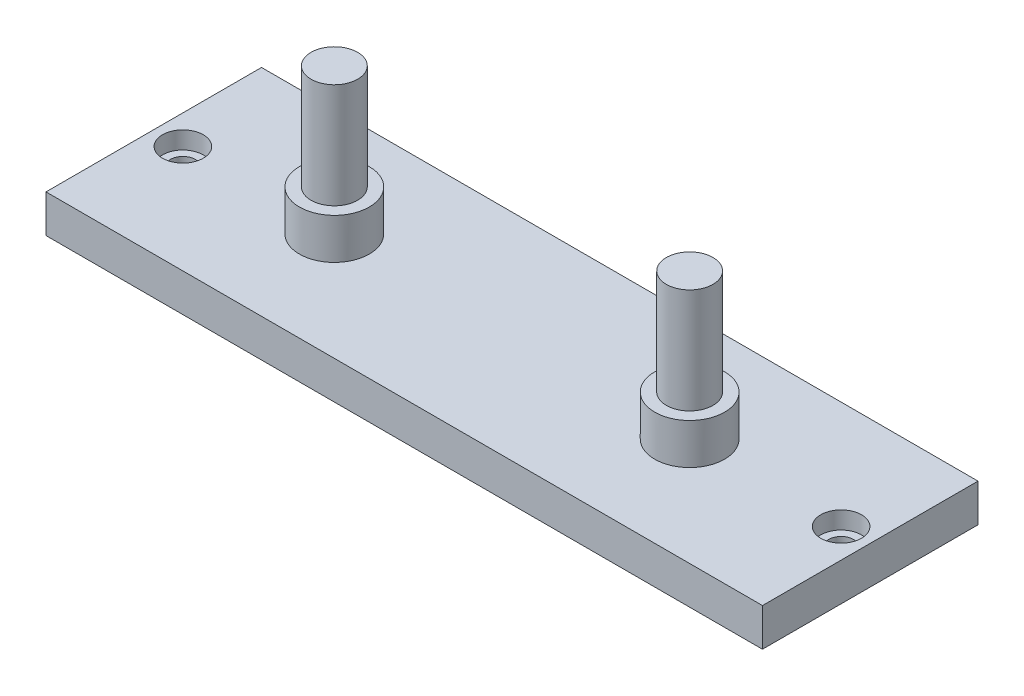
from build123d import *

# Parameters (mm, degrees)
SKETCH1_W                                        = 123
SKETCH1_H                                        = 37
BOSS_EXTRUDE1_DEPTH                              = 6.5
CBORE_FOR_M4_HEX_HEAD_MACHINE_SCREW1_D           = 4.3
CBORE_FOR_M4_HEX_HEAD_MACHINE_SCREW1_CBORE_D     = 7
CBORE_FOR_M4_HEX_HEAD_MACHINE_SCREW1_CBORE_DEPTH = 3
SKETCH7_R                                        = 4
BOSS_EXTRUDE2_DEPTH                              = 25
SKETCH8_R                                        = 6
BOSS_EXTRUDE3_DEPTH                              = 7


with BuildPart() as part:
    # Sketch1 → Boss-Extrude1 (new body)
    with BuildSketch(Plane(origin=(0, 0, 0), x_dir=(1, 0, 0), z_dir=(0, 1, 0))):
        with Locations((61.5, 18.5)):
            Rectangle(SKETCH1_W, SKETCH1_H)
    extrude(amount=BOSS_EXTRUDE1_DEPTH)

    # CBORE for M4 Hex Head Machine Screw1 (through all)
    with Locations(Plane(origin=(0, 6.5, 0), x_dir=(1, 0, 0), z_dir=(0, 1, 0))):
        with Locations((5, 18.5), (118, 18.5)):
            CounterBoreHole(CBORE_FOR_M4_HEX_HEAD_MACHINE_SCREW1_D / 2, CBORE_FOR_M4_HEX_HEAD_MACHINE_SCREW1_CBORE_D / 2, CBORE_FOR_M4_HEX_HEAD_MACHINE_SCREW1_CBORE_DEPTH)

    # Sketch7 → Boss-Extrude2 (add)
    with BuildSketch(Plane(origin=(0, 6.5, 0), x_dir=(1, 0, 0), z_dir=(0, 1, 0))):
        with Locations((31, 18.5)):
            Circle(SKETCH7_R)
        with Locations((92, 18.5)):
            Circle(SKETCH7_R)
    extrude(amount=BOSS_EXTRUDE2_DEPTH)

    # Sketch8 → Boss-Extrude3 (add)
    with BuildSketch(Plane(origin=(0, 6.5, 0), x_dir=(1, 0, 0), z_dir=(0, 1, 0))):
        with Locations((31, 18.5)):
            Circle(SKETCH8_R)
        with Locations((92, 18.5)):
            Circle(SKETCH8_R)
    extrude(amount=BOSS_EXTRUDE3_DEPTH)


solid = part.part
